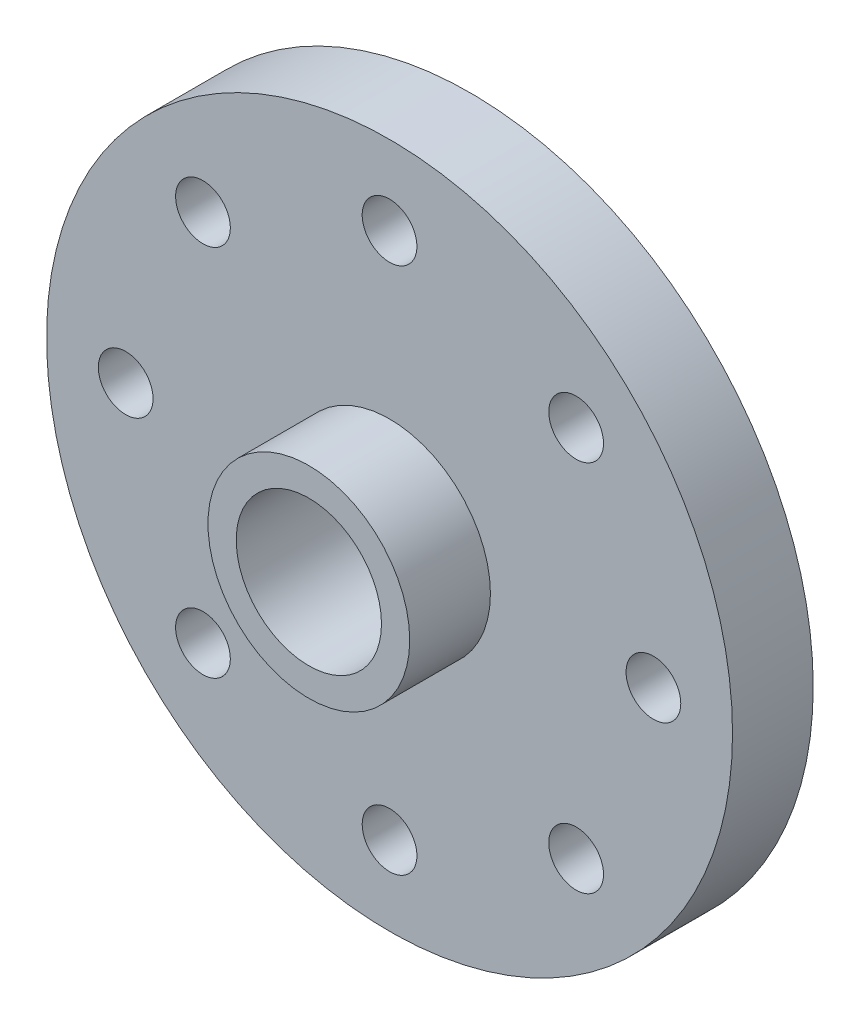
from build123d import *

# Parameters (mm, degrees)
SKETCH1_R           = 42.5
BOSS_EXTRUDE1_DEPTH = 10
SKETCH2_R           = 12.5
BOSS_EXTRUDE2_DEPTH = 10
SKETCH3_R           = 9
CUT_EXTRUDE1_DEPTH  = 20
SKETCH4_R           = 3.390899264
CUT_EXTRUDE2_DEPTH  = 10
CIRPATTERN1_COUNT   = 8


with BuildPart() as part:
    # Sketch1 → Boss-Extrude1 (new body)
    with BuildSketch(Plane.XY):
        Circle(SKETCH1_R)
    extrude(amount=BOSS_EXTRUDE1_DEPTH)

    # Sketch2 → Boss-Extrude2 (add)
    with BuildSketch(Plane.XY.offset(10)):
        Circle(SKETCH2_R)
    extrude(amount=BOSS_EXTRUDE2_DEPTH)

    # Sketch3 → Cut-Extrude1 (cut)
    with BuildSketch(Plane.XY.offset(20)):
        Circle(SKETCH3_R)
    extrude(amount=-CUT_EXTRUDE1_DEPTH, mode=Mode.SUBTRACT)

    # Sketch4 → Cut-Extrude2 (cut)
    with BuildSketch(Plane.XY.offset(10)):
        with Locations((0, 32.696600748)):
            Circle(SKETCH4_R)
    cut_extrude2 = extrude(amount=-CUT_EXTRUDE2_DEPTH, mode=Mode.SUBTRACT)

    # CirPattern1: Cut-Extrude2 ×8 about axis
    cirpattern1_axis = Axis((0, 0, 0), (0, 0, 1))
    for i in range(1, CIRPATTERN1_COUNT):
        add(cut_extrude2.rotate(cirpattern1_axis, i * 360 / CIRPATTERN1_COUNT), mode=Mode.SUBTRACT)


solid = part.part
